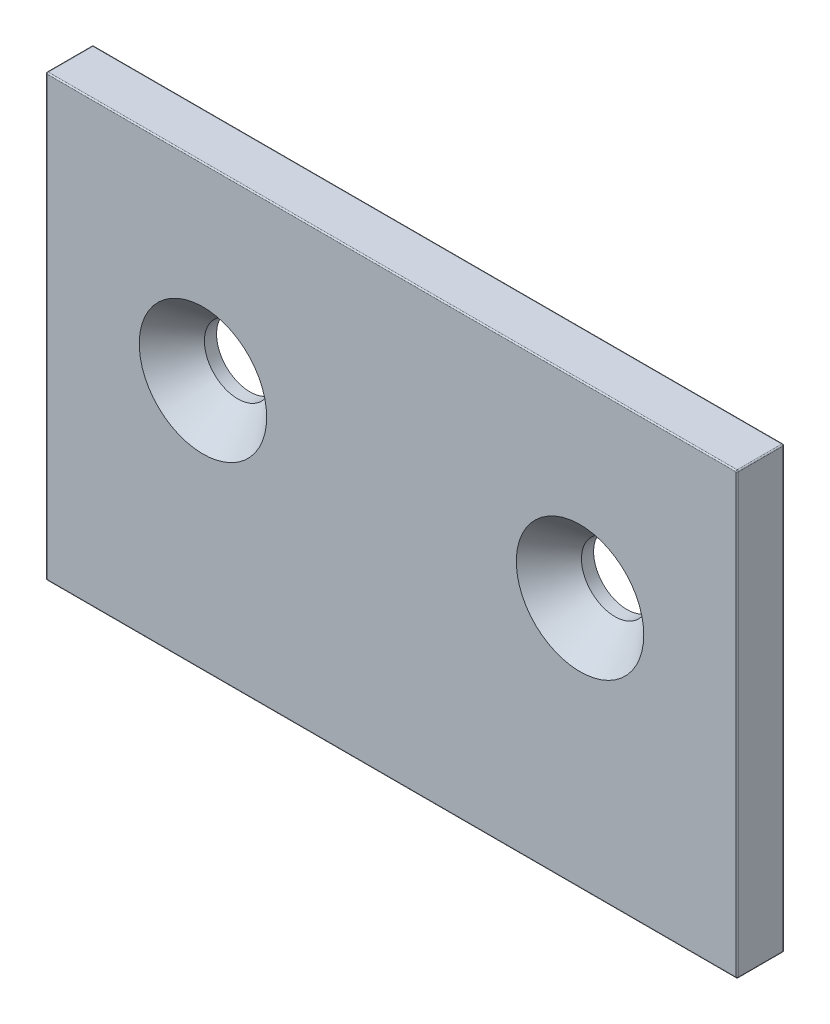
from build123d import *

# Parameters (mm, degrees)
SKETCH1_W                                     = 69.85
SKETCH1_H                                     = 44.45
BOSS_EXTRUDE1_DEPTH                           = 4.7498
CSK_FOR_1_4_FLAT_HEAD_MACHINE_SCREW1_AT_COUNT = 2
CSK_FOR_1_4_FLAT_HEAD_MACHINE_SCREW1_AT_PITCH = 38.1
FILLET1_R                                     = 0.127


with BuildPart() as part:
    # Sketch1 → Boss-Extrude1 (new body)
    with BuildSketch(Plane.XY):
        with Locations((0, 22.225)):
            Rectangle(SKETCH1_W, SKETCH1_H)
    extrude(amount=BOSS_EXTRUDE1_DEPTH)

    # Sketch4 → CSK for 1/4 Flat Head Machine Screw1 (revolve, cut)
    with BuildSketch(Plane(origin=(19.05, 25.4, 4.7498), x_dir=(0, -1, 0), z_dir=(1, 0, 0))):
        Polygon((0, 0), (0, 4.7498), (3.3782, 4.7498), (3.3782, 3.520932584), (6.4389, 0), align=None)
    csk_for_1_4_flat_head_machine_screw1 = revolve(axis=Axis((19.05, 25.4, 11.0998), (0, 0, -1)), mode=Mode.SUBTRACT)

    # CSK for 1/4 Flat Head Machine Screw1 at: CSK for 1/4 Flat Head Machine Screw1 ×2
    with Locations(*[(-i * CSK_FOR_1_4_FLAT_HEAD_MACHINE_SCREW1_AT_PITCH, 0, 0) for i in range(1, CSK_FOR_1_4_FLAT_HEAD_MACHINE_SCREW1_AT_COUNT)]):
        add(csk_for_1_4_flat_head_machine_screw1, mode=Mode.SUBTRACT)

    # Fillet1
    fillet1_edges = [part.edges().sort_by_distance(p)[0] for p in [
        (0, 44.45, 4.7498),
        (34.925, 22.225, 4.7498),
        (0, 0, 4.7498),
        (34.925, 22.225, 0),
        (0, 44.45, 0),
        (-34.925, 22.225, 0),
        (0, 0, 0),
        (34.925, 0, 2.3749),
        (34.925, 44.45, 2.3749),
        (-34.925, 44.45, 2.3749),
        (-34.925, 0, 2.3749),
        (-34.925, 22.225, 4.7498),
    ]]
    fillet(fillet1_edges, radius=FILLET1_R)


solid = part.part
